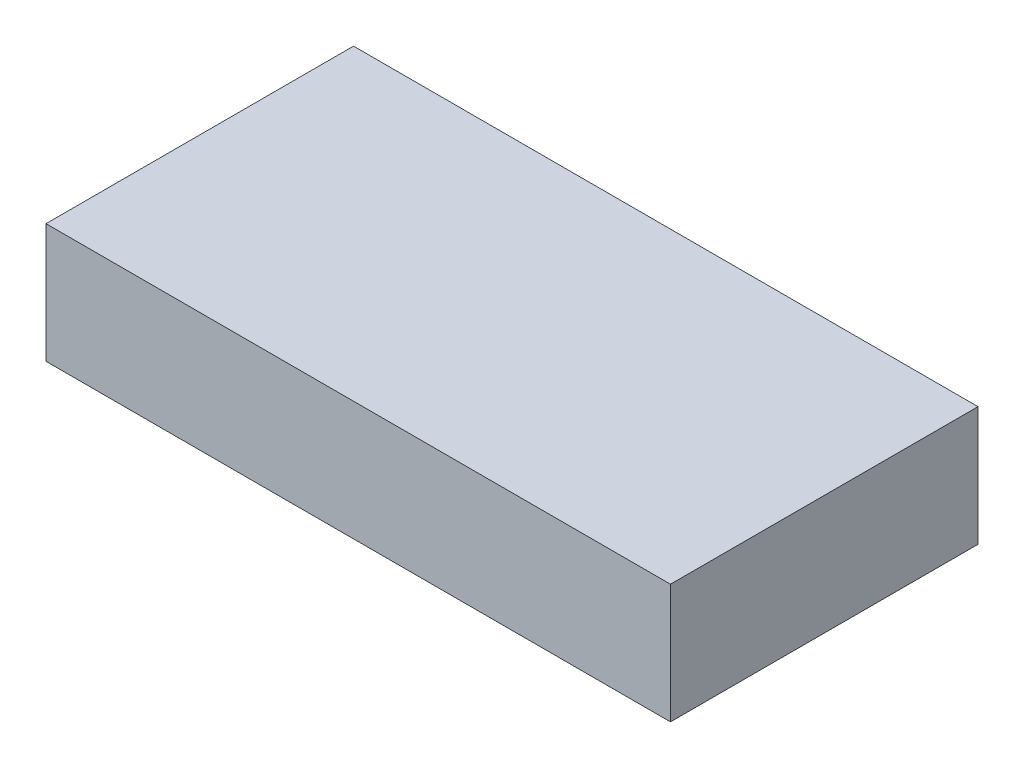
from build123d import *

# Parameters (mm, degrees)
SKETCH1_W           = 199
SKETCH1_H           = 98
BOSS_EXTRUDE1_DEPTH = 19


with BuildPart() as part:
    # Sketch1 → Boss-Extrude1 (new body, symmetric)
    with BuildSketch(Plane(origin=(0, 0, 0), x_dir=(1, 0, 0), z_dir=(0, 1, 0))):
        Rectangle(SKETCH1_W, SKETCH1_H)
    extrude(amount=BOSS_EXTRUDE1_DEPTH, both=True)


solid = part.part
